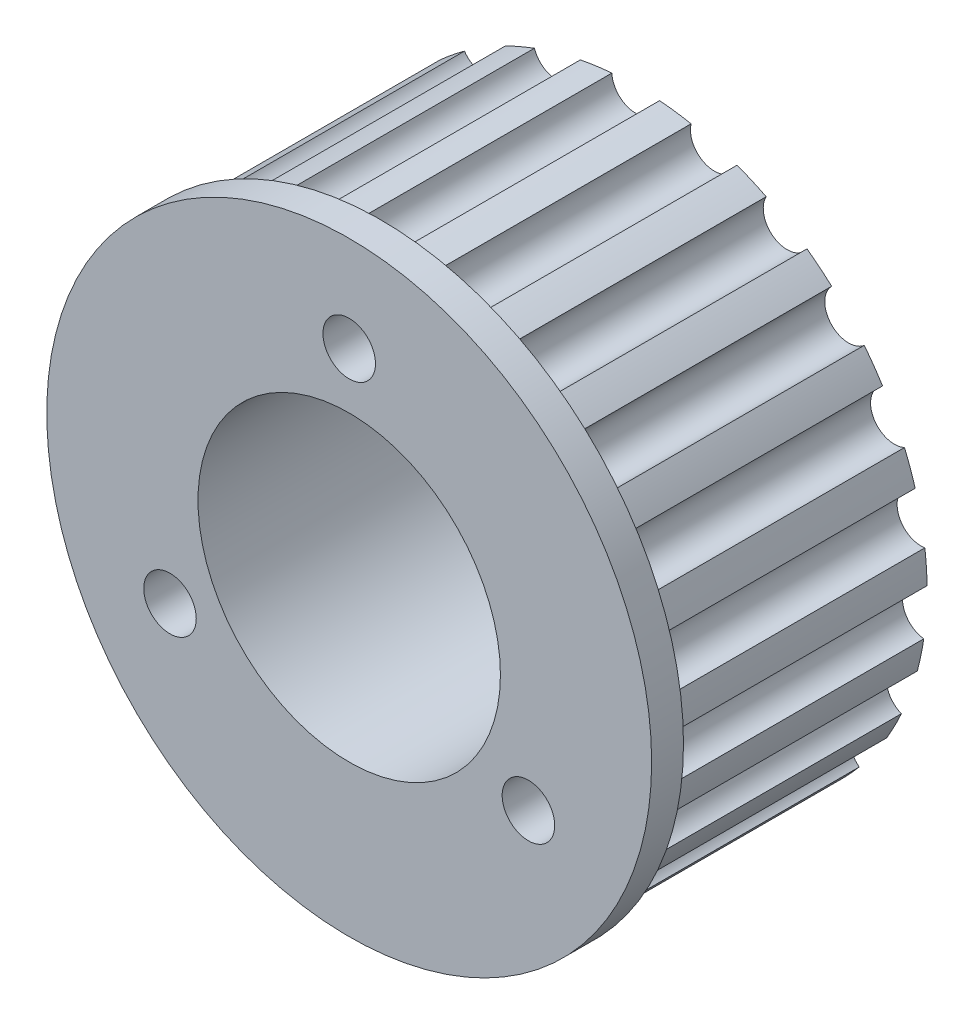
from build123d import *

# Parameters (mm, degrees)
SKETCH_1_R          = 9.5
EXTRUDE_1_DEPTH     = 16
SKETCH_2_R          = 19
SKETCH_2_R_2        = 9.5
EXTRUDE_2_DEPTH     = 2
SKETCH_4_R          = 1.65
CUT_EXTRUDE_1_DEPTH = 19


with BuildPart() as part:
    # Эскиз1 → Бобышка-Вытянуть1 (new body)
    with BuildSketch(Plane.XY):
        with BuildLine():
            ThreePointArc((-1.498740142, 18.241534666), (-2.492258178, 18.13252487), (-3.478344362, 17.969444329))
            ThreePointArc((-3.478344362, 17.969444329), (-4.533395146, 16.179899179), (-6.364669946, 17.160733827))
            ThreePointArc((-6.364669946, 17.160733827), (-7.291935147, 16.787718451), (-8.197455977, 16.364642511))
            ThreePointArc((-8.197455977, 16.364642511), (-8.730569112, 14.356809255), (-10.758561296, 14.807199865))
            ThreePointArc((-10.758561296, 14.807199865), (-11.550802645, 14.197843754), (-12.308599783, 13.54615002))
            ThreePointArc((-12.308599783, 13.54615002), (-12.280236708, 11.468940466), (-14.354539373, 11.355483627))
            ThreePointArc((-14.354539373, 11.355483627), (-14.952999952, 10.554979936), (-15.506871051, 9.723001553))
            ThreePointArc((-15.506871051, 9.723001553), (-14.919135325, 7.730472829), (-16.885906931, 7.061583116))
            ThreePointArc((-16.885906931, 7.061583116), (-17.246201658, 6.129301542), (-17.555068633, 5.17874254))
            ThreePointArc((-17.555068633, 5.17874254), (-16.451549925, 3.418671387), (-18.164924021, 2.243957291))
            ThreePointArc((-18.164924021, 2.243957291), (-18.260331482, 1.249040892), (-18.301287083, 0.250399884))
            ThreePointArc((-18.301287083, 0.250399884), (-16.763828329, -1.146677272), (-18.096731795, -2.740092582))
            ThreePointArc((-18.096731795, -2.740092582), (-17.920176057, -3.723855407), (-17.690182793, -4.696513786))
            ThreePointArc((-17.690182793, -4.696513786), (-15.832810274, -5.626982123), (-16.686387758, -7.520922323))
            ThreePointArc((-16.686387758, -7.520922323), (-16.250963152, -8.420570386), (-15.767078573, -9.295108514))
            ThreePointArc((-15.767078573, -9.295108514), (-13.727545112, -9.689959452), (-14.038490677, -11.743959661))
            ThreePointArc((-14.038490677, -11.743959661), (-13.376490654, -12.49277018), (-12.674602264, -13.204327565))
            ThreePointArc((-12.674602264, -13.204327565), (-10.604170729, -13.034276818), (-10.349422964, -15.096001236))
            ThreePointArc((-10.349422964, -15.096001236), (-9.509945037, -15.638438361), (-8.642108688, -16.134242047))
            ThreePointArc((-8.642108688, -16.134242047), (-6.694333513, -15.411901499), (-5.892785895, -17.328441459))
            ThreePointArc((-5.892785895, -17.328441459), (-4.938090302, -17.62427511), (-3.968669445, -17.867553605))
            ThreePointArc((-3.968669445, -17.867553605), (-2.288008205, -16.646495951), (-0.999107855, -18.275710451))
            ThreePointArc((-0.999107855, -18.275710451), (0, -18.303), (0.999107855, -18.275710451))
            ThreePointArc((0.999107855, -18.275710451), (2.288008205, -16.646495951), (3.968669445, -17.867553605))
            ThreePointArc((3.968669445, -17.867553605), (4.938090302, -17.62427511), (5.892785895, -17.328441459))
            ThreePointArc((5.892785895, -17.328441459), (6.694333513, -15.411901499), (8.642108688, -16.134242047))
            ThreePointArc((8.642108688, -16.134242047), (9.509945037, -15.638438361), (10.349422964, -15.096001236))
            ThreePointArc((10.349422964, -15.096001236), (10.604170729, -13.034276818), (12.674602264, -13.204327565))
            ThreePointArc((12.674602264, -13.204327565), (13.376490654, -12.49277018), (14.038490677, -11.743959661))
            ThreePointArc((14.038490677, -11.743959661), (13.727545112, -9.689959452), (15.767078573, -9.295108514))
            ThreePointArc((15.767078573, -9.295108514), (16.250963152, -8.420570386), (16.686387758, -7.520922323))
            ThreePointArc((16.686387758, -7.520922323), (15.832810274, -5.626982123), (17.690182793, -4.696513786))
            ThreePointArc((17.690182793, -4.696513786), (17.920176057, -3.723855407), (18.096731795, -2.740092582))
            ThreePointArc((18.096731795, -2.740092582), (16.763828329, -1.146677272), (18.301287083, 0.250399884))
            ThreePointArc((18.301287083, 0.250399884), (18.260331482, 1.249040892), (18.164924021, 2.243957291))
            ThreePointArc((18.164924021, 2.243957291), (16.451549925, 3.418671387), (17.555068633, 5.17874254))
            ThreePointArc((17.555068633, 5.17874254), (17.246201658, 6.129301542), (16.885906931, 7.061583116))
            ThreePointArc((16.885906931, 7.061583116), (14.919135325, 7.730472829), (15.506871051, 9.723001553))
            ThreePointArc((15.506871051, 9.723001553), (14.952999952, 10.554979936), (14.354539373, 11.355483627))
            ThreePointArc((14.354539373, 11.355483627), (12.280236708, 11.468940466), (12.308599783, 13.54615002))
            ThreePointArc((12.308599783, 13.54615002), (11.550802645, 14.197843754), (10.758561296, 14.807199865))
            ThreePointArc((10.758561296, 14.807199865), (8.730569112, 14.356809255), (8.197455977, 16.364642511))
            ThreePointArc((8.197455977, 16.364642511), (7.291935147, 16.787718451), (6.364669946, 17.160733827))
            ThreePointArc((6.364669946, 17.160733827), (4.533395146, 16.179899179), (3.478344362, 17.969444329))
            ThreePointArc((3.478344362, 17.969444329), (2.492258178, 18.13252487), (1.498740142, 18.241534666))
            ThreePointArc((1.498740142, 18.241534666), (0, 16.803), (-1.498740142, 18.241534666))
        make_face()
        Circle(SKETCH_1_R, mode=Mode.SUBTRACT)
    extrude(amount=EXTRUDE_1_DEPTH)

    # Эскиз2 → Бобышка-Вытянуть2 (add)
    with BuildSketch(Plane.XY.offset(16)):
        Circle(SKETCH_2_R)
        Circle(SKETCH_2_R_2, mode=Mode.SUBTRACT)
    extrude(amount=EXTRUDE_2_DEPTH)

    # Эскиз4 → Вырез-Вытянуть1 (cut, through all)
    with BuildSketch(Plane.XY.offset(18)):
        with Locations((0, 13)):
            Circle(SKETCH_4_R)
        with Locations((11.258330249, -6.5)):
            Circle(SKETCH_4_R)
        with Locations((-11.258330249, -6.5)):
            Circle(SKETCH_4_R)
    extrude(amount=-CUT_EXTRUDE_1_DEPTH, mode=Mode.SUBTRACT)


solid = part.part
